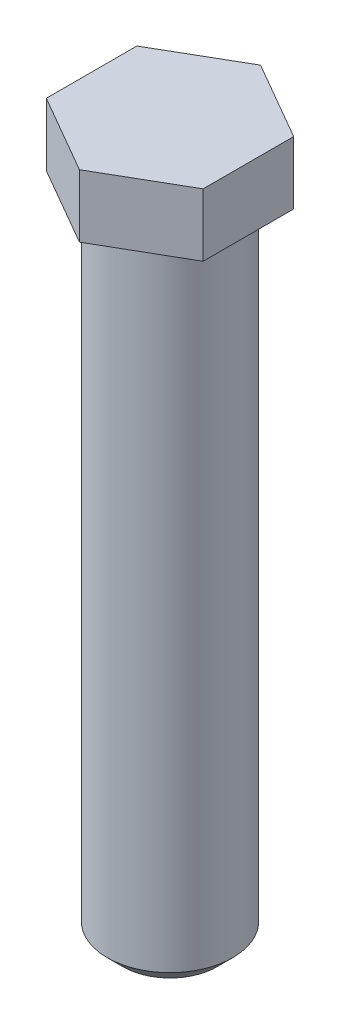
from build123d import *

# Parameters (mm, degrees)
SKETCH1_R           = 2
BOSS_EXTRUDE1_DEPTH = 20.7
BOSS_EXTRUDE2_DEPTH = 2
CHAMFER1_SIZE       = 0.5
FILLET1_R           = 0.2


with BuildPart() as part:
    # Sketch1 → Boss-Extrude1 (new body)
    with BuildSketch(Plane(origin=(0, 0, 0), x_dir=(1, 0, 0), z_dir=(0, 1, 0))):
        Circle(SKETCH1_R)
    extrude(amount=BOSS_EXTRUDE1_DEPTH)

    # Sketch2 → Boss-Extrude2 (add)
    with BuildSketch(Plane(origin=(0, 20.7, 0), x_dir=(1, 0, 0), z_dir=(0, 1, 0))):
        Polygon((0, 2.886751346), (-2.5, 1.443375673), (-2.5, -1.443375673), (0, -2.886751346), (2.5, -1.443375673), (2.5, 1.443375673), align=None)
    extrude(amount=BOSS_EXTRUDE2_DEPTH)

    # Chamfer1
    chamfer1_edges = [part.edges().sort_by_distance(p)[0] for p in [
        (-2, 0, 0),
    ]]
    chamfer(chamfer1_edges, length=CHAMFER1_SIZE)

    # Fillet1
    fillet1_edges = [part.edges().sort_by_distance(p)[0] for p in [
        (-2, 20.7, 0),
    ]]
    fillet(fillet1_edges, radius=FILLET1_R)


solid = part.part
